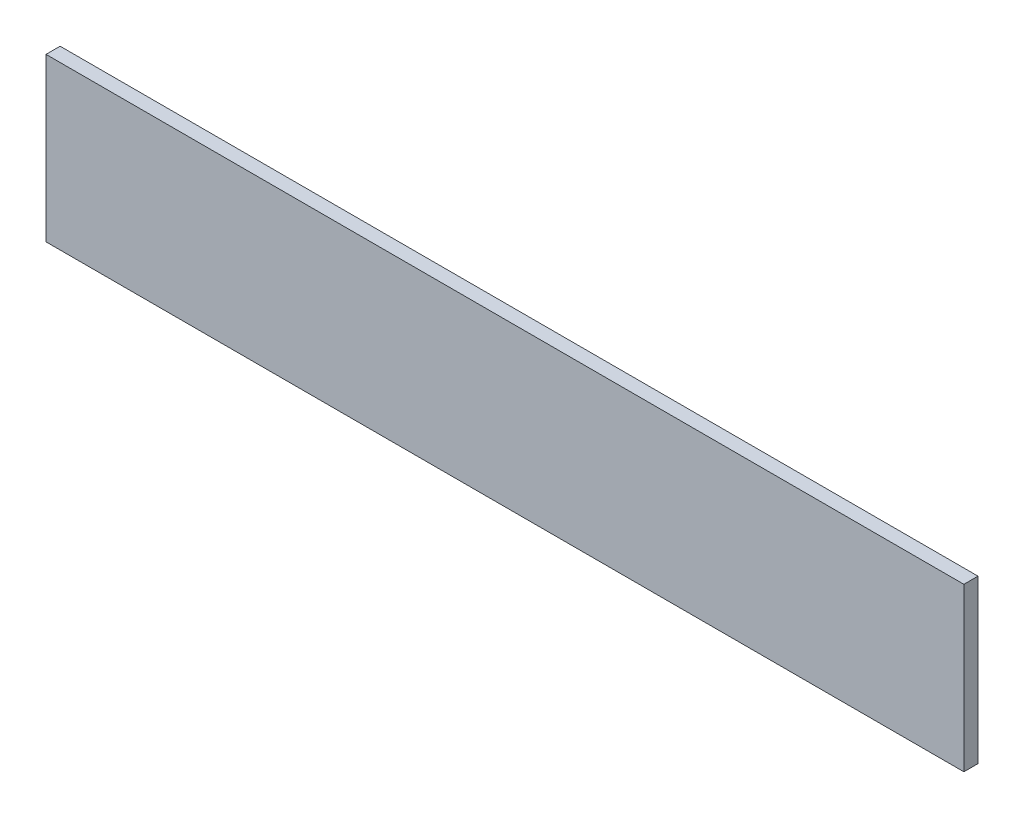
from build123d import *

# Parameters (mm, degrees)
SKETCH_1_W      = 260
SKETCH_1_H      = 46
EXTRUDE_1_DEPTH = 4


with BuildPart() as part:
    # Эскиз1 → Вытянуть1 (new body)
    with BuildSketch(Plane.XY):
        with Locations((130, 23)):
            Rectangle(SKETCH_1_W, SKETCH_1_H)
    extrude(amount=EXTRUDE_1_DEPTH)


solid = part.part
